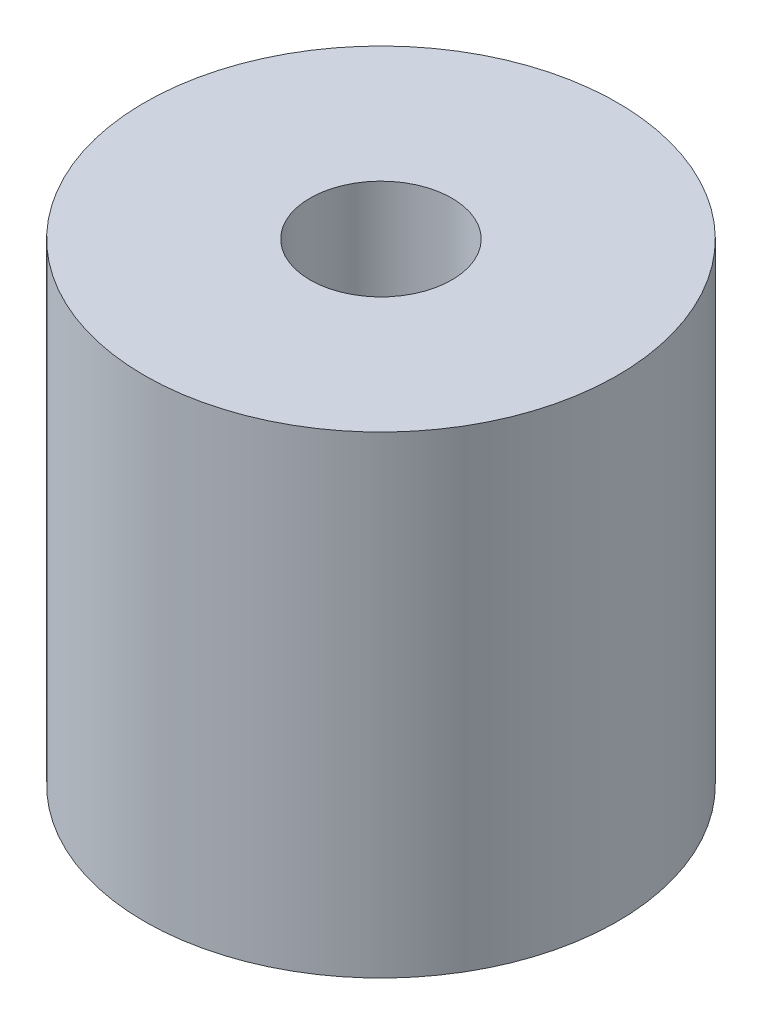
from build123d import *

# Parameters (mm, degrees)
SKETCH1_R           = 5
SKETCH1_R_2         = 1.5
BOSS_EXTRUDE1_DEPTH = 10


with BuildPart() as part:
    # Sketch1 → Boss-Extrude1 (new body)
    with BuildSketch(Plane(origin=(0, 0, 0), x_dir=(1, 0, 0), z_dir=(0, 1, 0))):
        Circle(SKETCH1_R)
        Circle(SKETCH1_R_2, mode=Mode.SUBTRACT)
    extrude(amount=BOSS_EXTRUDE1_DEPTH)


solid = part.part
